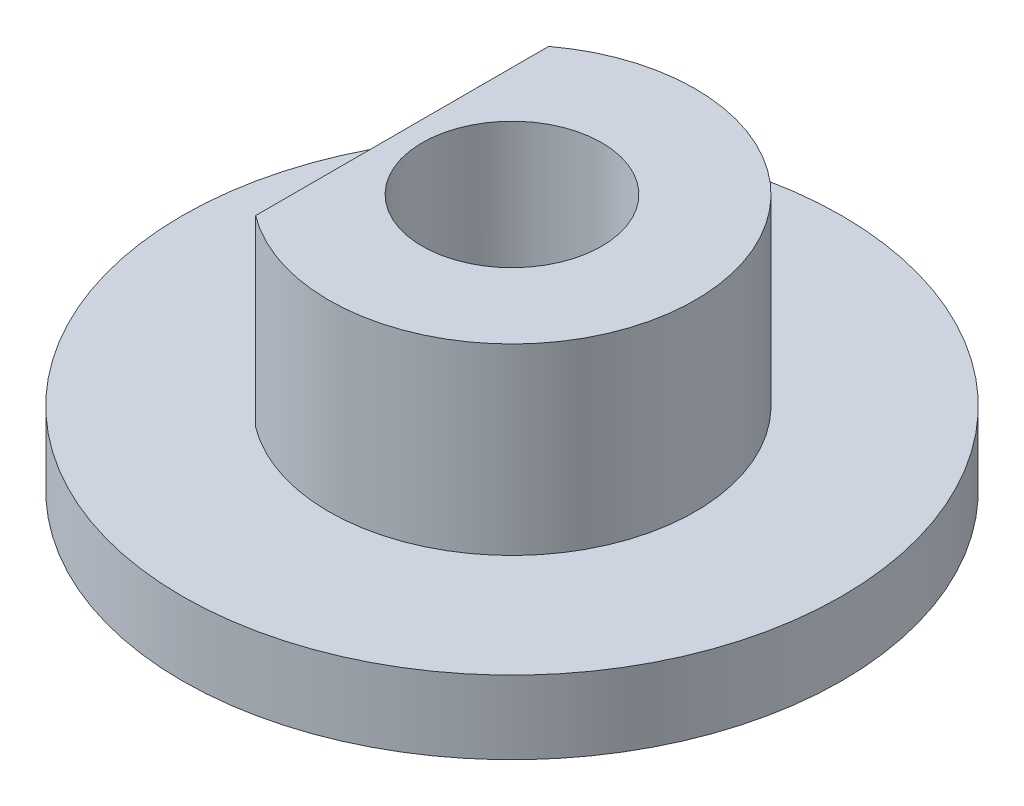
from build123d import *

# Parameters (mm, degrees)
KEY_EXTRUDE_DEPTH         = 7
SKETCH1_6_R               = 9
BASE_EXTRUDE_DEPTH        = 2
MOTORSHAFT_CUT_DEPTH      = 15.525839046
MOTORSHAFT_CUT_DEPTH_BACK = 15.525839046
SKETCH2_R                 = 2.45


with BuildPart() as part:
    # Sketch1 → key-Extrude (new body)
    with BuildSketch(Plane(origin=(0, 0, 0), x_dir=(1, 0, 0), z_dir=(0, 1, 0))):
        with BuildLine():
            ThreePointArc((5, 0), (2.236067977, 4.472135955), (-3, 4))
            Line((-3, 4), (-3, -4))
            ThreePointArc((-3, -4), (2.236067977, -4.472135955), (5, 0))
        make_face()
    extrude(amount=KEY_EXTRUDE_DEPTH)


with BuildPart() as body_2:
    # Sketch1_6 → base-Extrude (new body)
    with BuildSketch(Plane(origin=(0, 0, 0), x_dir=(1, 0, 0), z_dir=(0, 1, 0))):
        Circle(SKETCH1_6_R)
    extrude(amount=BASE_EXTRUDE_DEPTH)


with BuildPart() as motorshaft_cut_tool:
    # Sketch2 → motorshaft-Cut (new, two sides: drawn at the far end of the back side and taken through both)
    with BuildSketch(Plane.XZ.offset(-MOTORSHAFT_CUT_DEPTH_BACK)):
        Circle(SKETCH2_R)
    extrude(amount=MOTORSHAFT_CUT_DEPTH + MOTORSHAFT_CUT_DEPTH_BACK)


with BuildPart() as part_1:
    add(part.part)

    # motorshaft-Cut: cut by motorshaft_cut_tool
    add(motorshaft_cut_tool.part, mode=Mode.SUBTRACT)


with BuildPart() as body_2_1:
    add(body_2.part)

    # motorshaft-Cut: cut by motorshaft_cut_tool
    add(motorshaft_cut_tool.part, mode=Mode.SUBTRACT)


solid = Compound([part_1.part, body_2_1.part])
